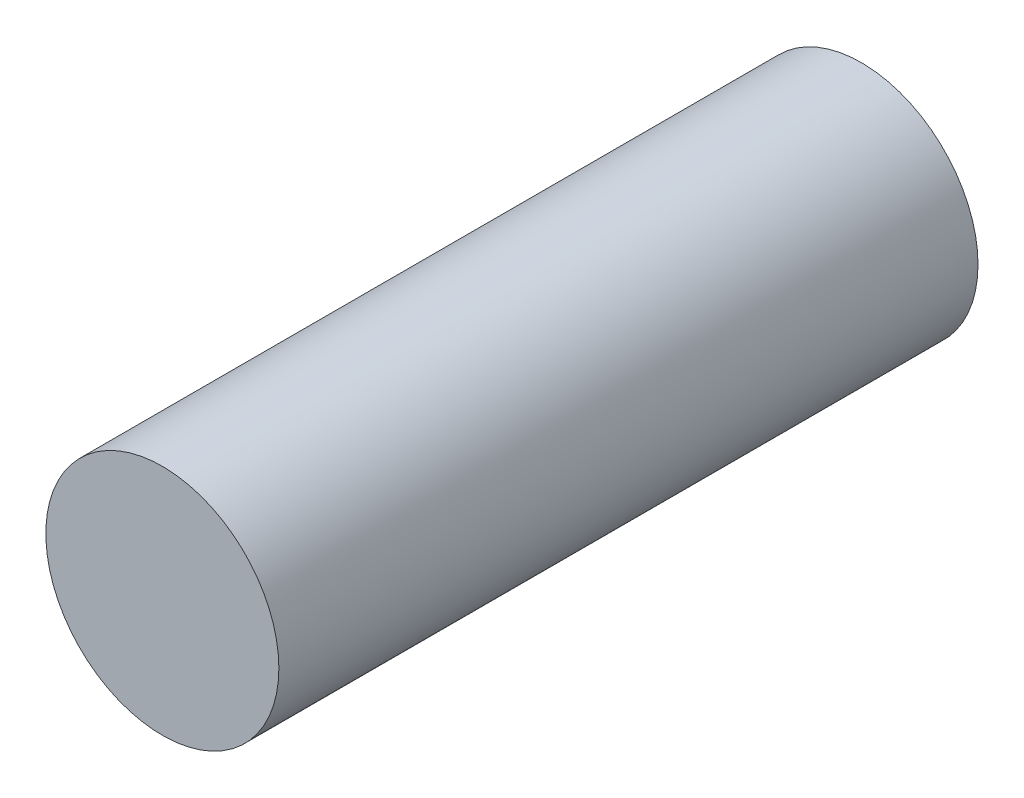
from build123d import *

# Parameters (mm, degrees)
SKETCH1_R           = 5
BOSS_EXTRUDE1_DEPTH = 30


with BuildPart() as part:
    # Sketch1 → Boss-Extrude1 (new body)
    with BuildSketch(Plane.XY):
        Circle(SKETCH1_R)
    extrude(amount=BOSS_EXTRUDE1_DEPTH)


solid = part.part
